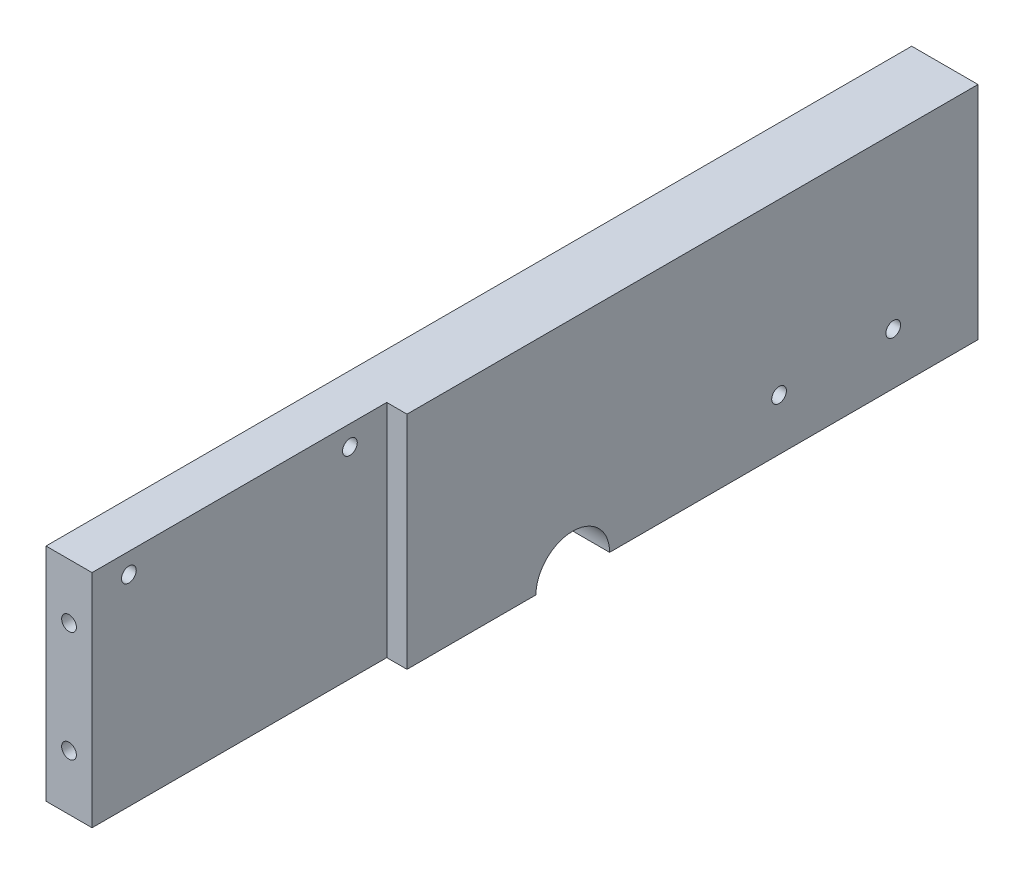
from build123d import *

# Parameters (mm, degrees)
ESQUISSE1_W             = 80
ESQUISSE1_H             = 60
ESQUISSE1_R             = 2
BOSS_EXTRU_2_DEPTH      = 12.5
ESQUISSE1_3_R           = 2
BOSS_EXTRU_3_DEPTH      = 18
ESQUISSE5_R             = 2
ENL_V_MAT_EXTRU_2_DEPTH = 10


with BuildPart() as part:
    # Esquisse1 → Boss.-Extru.2 (new body)
    with BuildSketch(Plane(origin=(0, 0, 0), x_dir=(0, 0, -1), z_dir=(1, 0, 0))):
        with Locations((-24.826777374, -19.395329297)):
            Rectangle(ESQUISSE1_W, ESQUISSE1_H)
        with Locations((-54.826777374, 5.154670703)):
            Circle(ESQUISSE1_R, mode=Mode.SUBTRACT)
        with Locations((5.173222626, 5.154670703)):
            Circle(ESQUISSE1_R, mode=Mode.SUBTRACT)
    extrude(amount=BOSS_EXTRU_2_DEPTH)

    # Esquisse1_3 → Boss.-Extru.3 (add)
    with BuildSketch(Plane(origin=(0, 0, 0), x_dir=(0, 0, -1), z_dir=(1, 0, 0))):
        with BuildLine():
            Line((170.173222626, 10.604670703), (15.173222626, 10.604670703))
            Line((15.173222626, 10.604670703), (15.173222626, -49.395329297))
            Line((15.173222626, -49.395329297), (50.173222626, -49.395329297))
            ThreePointArc((50.173222626, -49.395329297), (60.173222626, -39.395329297), (70.173222626, -49.395329297))
            Line((70.173222626, -49.395329297), (170.173222626, -49.395329297))
            Line((170.173222626, -49.395329297), (170.173222626, 10.604670703))
        make_face()
        with Locations((116.173222626, -35.395329297)):
            Circle(ESQUISSE1_3_R, mode=Mode.SUBTRACT)
        with Locations((147.173222626, -35.395329297)):
            Circle(ESQUISSE1_3_R, mode=Mode.SUBTRACT)
    extrude(amount=BOSS_EXTRU_3_DEPTH)

    # Esquisse5 → Enlèv. mat.-Extru.2 (cut)
    with BuildSketch(Plane.XY.offset(64.826777374)):
        with Locations((6.25, -4.395329297)):
            Circle(ESQUISSE5_R)
        with Locations((6.25, -34.395329297)):
            Circle(ESQUISSE5_R)
    extrude(amount=-ENL_V_MAT_EXTRU_2_DEPTH, mode=Mode.SUBTRACT)


solid = part.part
